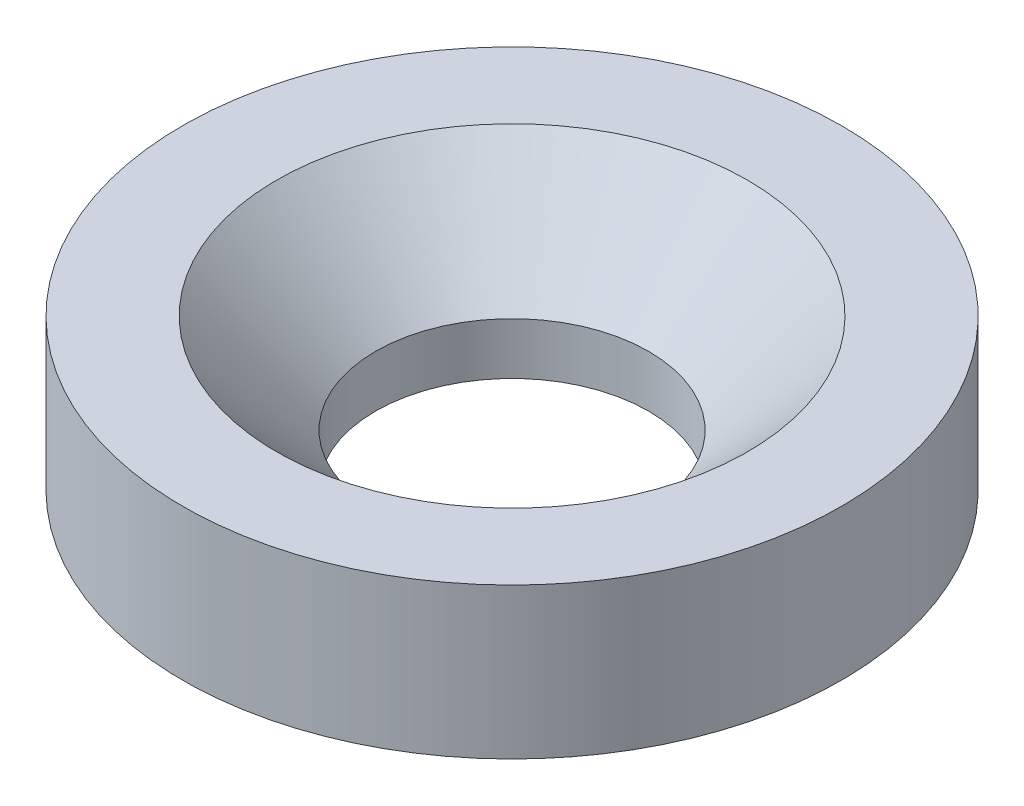
from build123d import *


with BuildPart() as part:
    # Sketch2 → Revolve1 (revolve)
    with BuildSketch(Plane.XY):
        Polygon((7.25, 0), (17.5, 0), (17.5, 8), (12.5, 8), (7.25, 2.75), align=None)
    revolve(axis=Axis((0, 0, 0), (0, 1, 0)))


solid = part.part
